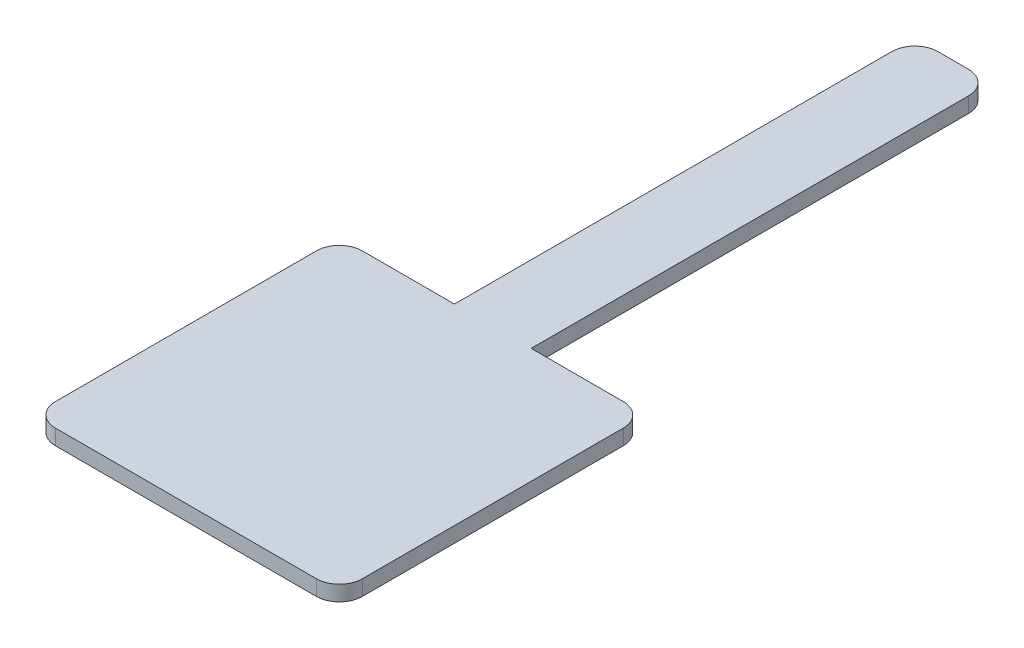
from build123d import *

# Parameters (mm, degrees)
EXTRUDE_1_DEPTH = 1
FILLET_1_R      = 1.5


with BuildPart() as part:
    # 草图1 → 凸台-拉伸1 (new body)
    with BuildSketch(Plane(origin=(0, 0, 0), x_dir=(1, 0, 0), z_dir=(0, 1, 0))):
        Polygon((-24.804006769, -20.720140696), (-4.804006769, -20.720140696), (-4.804006769, -0.720140696), (-12.304006769, -0.720140696), (-12.304006769, 29.279859304), (-17.304006769, 29.279859304), (-17.304006769, -0.720140696), (-24.804006769, -0.720140696), align=None)
    extrude(amount=EXTRUDE_1_DEPTH)

    # 圆角1
    fillet_1_edges = [part.edges().sort_by_distance(p)[0] for p in [
        (-24.804006769, 0.5, 0.720140696),
        (-17.304006769, 0.5, -29.279859304),
        (-12.304006769, 0.5, -29.279859304),
        (-4.804006769, 0.5, 0.720140696),
        (-4.804006769, 0.5, 20.720140696),
        (-24.804006769, 0.5, 20.720140696),
    ]]
    fillet(fillet_1_edges, radius=FILLET_1_R)


solid = part.part
